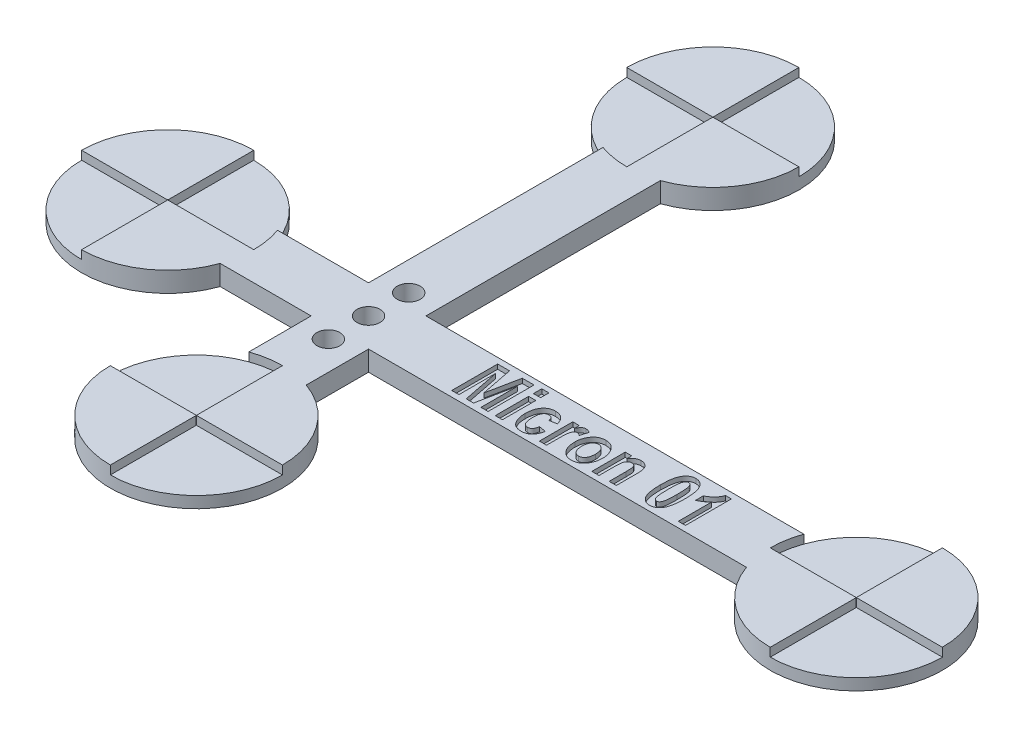
from build123d import *

# Parameters (mm, degrees)
BOSS_EXTRUDE1_DEPTH = 3.5
CUT_EXTRUDE1_DEPTH  = 1.5
SKETCH3_W           = 1.246753247
SKETCH3_H           = 1.454545455
SKETCH3_H_2         = 5.818181818
CUT_EXTRUDE2_DEPTH  = 0.8
SKETCH4_R           = 2
CUT_EXTRUDE3_DEPTH  = 4.5


with BuildPart() as part:
    # Sketch1 → Boss-Extrude1 (new body)
    with BuildSketch(Plane(origin=(0, 0, 0), x_dir=(1, 0, 0), z_dir=(0, 1, 0))):
        with BuildLine():
            Line((30, 45.857864376), (30, 5))
            Line((30, 5), (14.142135624, 5))
            ThreePointArc((14.142135624, 5), (-15, 0), (14.142135624, -5))
            Line((14.142135624, -5), (30, -5))
            Line((30, -5), (30, -15.857864376))
            ThreePointArc((30, -15.857864376), (35, -45), (40, -15.857864376))
            Line((40, -15.857864376), (40, -5))
            Line((40, -5), (105.857864376, -5))
            ThreePointArc((105.857864376, -5), (135, 0), (105.857864376, 5))
            Line((105.857864376, 5), (40, 5))
            Line((40, 5), (40, 45.857864376))
            ThreePointArc((40, 45.857864376), (35, 75), (30, 45.857864376))
        make_face()
    extrude(amount=BOSS_EXTRUDE1_DEPTH)

    # Sketch2 → Cut-Extrude1 (cut)
    with BuildSketch(Plane(origin=(0, 3.5, 0), x_dir=(1, 0, 0), z_dir=(0, 1, 0))):
        with BuildLine():
            Line((-15, 0), (-0.05, 0))
            ThreePointArc((-0.05, 0), (-0.035355339, 0.035355339), (0, 0.05))
            Line((0, 0.05), (0, 15))
            ThreePointArc((0, 15), (10.606601718, 10.606601718), (15, 0))
            Line((15, 0), (0.05, 0))
            ThreePointArc((0.05, 0), (0.035355339, -0.035355339), (0, -0.05))
            Line((0, -0.05), (0, -15))
            ThreePointArc((0, -15), (-10.606601718, -10.606601718), (-15, 0))
        make_face()
        with BuildLine():
            Line((35, 75), (35, 60.05))
            ThreePointArc((35, 60.05), (34.964644661, 60.035355339), (34.95, 60))
            Line((34.95, 60), (20, 60))
            ThreePointArc((20, 60), (24.393398282, 49.393398282), (35, 45))
            Line((35, 45), (35, 59.95))
            ThreePointArc((35, 59.95), (35.035355339, 59.964644661), (35.05, 60))
            Line((35.05, 60), (50, 60))
            ThreePointArc((50, 60), (45.606601718, 70.606601718), (35, 75))
        make_face()
        with BuildLine():
            Line((120, 15), (120, 0.05))
            ThreePointArc((120, 0.05), (120.035355339, 0.035355339), (120.05, 0))
            Line((120.05, 0), (135, 0))
            ThreePointArc((135, 0), (130.606601718, -10.606601718), (120, -15))
            Line((120, -15), (120, -0.05))
            ThreePointArc((120, -0.05), (119.964644661, -0.035355339), (119.95, 0))
            Line((119.95, 0), (105, 0))
            ThreePointArc((105, 0), (109.393398282, 10.606601718), (120, 15))
        make_face()
        with BuildLine():
            Line((20, -30), (34.95, -30))
            ThreePointArc((34.95, -30), (34.964644661, -30.035355339), (35, -30.05))
            Line((35, -30.05), (35, -45))
            ThreePointArc((35, -45), (45.606601718, -40.606601718), (50, -30))
            Line((50, -30), (35.05, -30))
            ThreePointArc((35.05, -30), (35.035355339, -29.964644661), (35, -29.95))
            Line((35, -29.95), (35, -15))
            ThreePointArc((35, -15), (24.393398282, -19.393398282), (20, -30))
        make_face()
    extrude(amount=-CUT_EXTRUDE1_DEPTH, mode=Mode.SUBTRACT)

    # Sketch3 → Cut-Extrude2 (cut)
    with BuildSketch(Plane(origin=(0, 3.5, 0), x_dir=(1, 0, 0), z_dir=(0, 1, 0))):
        Polygon((53.50036076, -4), (53.50036076, 4), (55.563672448, 4), (56.669191928, -1.561688312), (57.795815305, 4), (59.838023097, 4), (59.838023097, -4), (58.59126985, -4), (58.59126985, 2.400974026), (57.290945175, -4), (56.023088032, -4), (54.747114006, 2.400974026), (54.747114006, -4), align=None)
        with Locations((61.708152968, 3.376623377)):
            Rectangle(SKETCH3_W, SKETCH3_H)
        with Locations((61.708152968, -1.090909091)):
            Rectangle(SKETCH3_W, SKETCH3_H_2)
        with BuildLine():
            Line((67.734126993, 0.155844156), (66.487373747, -0.051948052))
            add(Edge.make_bspline(
                [(66.487373747, -0.051948052), (66.475238631, 0.013492139), (66.452160271, 0.137945199), (66.389179941, 0.307989308), (66.312160634, 0.454611766), (66.213055442, 0.573886506), (66.095416345, 0.667213464), (65.958609537, 0.733166985), (65.803936467, 0.772456922), (65.694860886, 0.776912369), (65.638347773, 0.779220779)],
                knots=[0, 0, 0, 0, 0.000199325, 0.000379073, 0.0005418, 0.000693948, 0.000840745, 0.000988855, 0.001146348, 0.001315678, 0.001315678, 0.001315678, 0.001315678], degree=3))
            add(Edge.make_bspline(
                [(65.638347773, 0.779220779), (65.600905429, 0.778062939), (65.527122523, 0.775781331), (65.420010496, 0.755102855), (65.317553938, 0.725549098), (65.222958212, 0.677663569), (65.130758823, 0.622007918), (65.046957124, 0.549315551), (64.968136169, 0.465515202), (64.894709448, 0.369037743), (64.827095322, 0.257785931), (64.770603047, 0.128257783), (64.725083376, -0.018687378), (64.68335517, -0.181979253), (64.653655963, -0.363419746), (64.633180941, -0.562384664), (64.620101663, -0.77850796), (64.618220871, -0.928551854), (64.617243876, -1.006493506)],
                knots=[0, 0, 0, 0, 0.000112201, 0.0002211, 0.00032637, 0.000430923, 0.000538128, 0.000648708, 0.000762403, 0.000882861, 0.001011764, 0.001152033, 0.001305535, 0.001472868, 0.001657284, 0.001856457, 0.002072757, 0.002306574, 0.002306574, 0.002306574, 0.002306574], degree=3))
            add(Edge.make_bspline(
                [(64.617243876, -1.006493506), (64.618261217, -1.092546265), (64.620213954, -1.257720471), (64.632711779, -1.496116795), (64.65538517, -1.714396148), (64.685469478, -1.914085761), (64.725675307, -2.093641007), (64.774055334, -2.254680712), (64.831596703, -2.395907747), (64.899086485, -2.518208897), (64.974173657, -2.623094471), (65.056196277, -2.712538943), (65.142228328, -2.791034021), (65.2374127, -2.851962864), (65.336627186, -2.901864568), (65.442857496, -2.935934853), (65.55464497, -2.95784839), (65.631749283, -2.959966029), (65.670815305, -2.961038961)],
                knots=[0, 0, 0, 0, 0.000258163, 0.000495531, 0.000715862, 0.000916302, 0.00110101, 0.001267389, 0.001420236, 0.001557572, 0.001685521, 0.001806187, 0.001921184, 0.002033748, 0.002144102, 0.002253448, 0.002367432, 0.002484495, 0.002484495, 0.002484495, 0.002484495], degree=3))
            add(Edge.make_bspline(
                [(65.670815305, -2.961038961), (65.72855094, -2.958115137), (65.840148837, -2.952463643), (65.998917272, -2.902884688), (66.141871425, -2.82385793), (66.244914469, -2.730611667), (66.318466989, -2.639969699), (66.370108431, -2.557981246), (66.418545215, -2.464077917), (66.462084604, -2.358060987), (66.501266248, -2.240396767), (66.534349316, -2.110465037), (66.565645908, -1.968673701), (66.582502685, -1.869672225), (66.59126985, -1.818181818)],
                knots=[0, 0, 0, 0, 0.000172842, 0.000334088, 0.000493972, 0.000659525, 0.000747247, 0.000843616, 0.000949622, 0.001063883, 0.001187088, 0.001321358, 0.001465921, 0.001622591, 0.001622591, 0.001622591, 0.001622591], degree=3))
            Line((66.59126985, -1.818181818), (67.838023097, -2.025974026))
            add(Edge.make_bspline(
                [(67.838023097, -2.025974026), (67.821015846, -2.110033143), (67.787894315, -2.273737832), (67.725282574, -2.51019173), (67.648292222, -2.729306841), (67.562922764, -2.933353422), (67.465367894, -3.120817392), (67.35648555, -3.292169834), (67.236010198, -3.447294215), (67.103969601, -3.586117196), (66.960430352, -3.708703947), (66.805564143, -3.814231607), (66.640086257, -3.904896068), (66.462835354, -3.977226655), (66.274845438, -4.034537616), (66.075882267, -4.074640125), (65.865713047, -4.099528833), (65.721752457, -4.102417816), (65.648088032, -4.103896104)],
                knots=[0, 0, 0, 0, 0.000257263, 0.000501018, 0.000733076, 0.000953485, 0.001164055, 0.001366255, 0.001561742, 0.001752349, 0.001940051, 0.002126916, 0.002313611, 0.002505046, 0.002700189, 0.002902356, 0.003113183, 0.003334111, 0.003334111, 0.003334111, 0.003334111], degree=3))
            add(Edge.make_bspline(
                [(65.648088032, -4.103896104), (65.554819841, -4.101887492), (65.37321271, -4.097976423), (65.110471697, -4.053593587), (64.864673186, -3.987367001), (64.639207309, -3.888476021), (64.431834059, -3.764176577), (64.243759839, -3.611361294), (64.073517705, -3.431602628), (63.925921273, -3.224317401), (63.795814013, -2.999463478), (63.681997355, -2.762165056), (63.585965745, -2.513438303), (63.506034653, -2.254410985), (63.446476255, -1.98270864), (63.403410095, -1.700737492), (63.374039392, -1.407542533), (63.371686907, -1.208406699), (63.37049063, -1.107142857)],
                knots=[0, 0, 0, 0, 0.000279523, 0.000544272, 0.000797144, 0.001041429, 0.001280302, 0.001520398, 0.001766145, 0.002020725, 0.002281892, 0.002544739, 0.002809429, 0.003081077, 0.00335717, 0.003643018, 0.003936526, 0.004240206, 0.004240206, 0.004240206, 0.004240206], degree=3))
            add(Edge.make_bspline(
                [(63.37049063, -1.107142857), (63.372239743, -0.987488549), (63.375640625, -0.75483916), (63.405336818, -0.417027711), (63.452726945, -0.100401237), (63.522926455, 0.193547978), (63.609847208, 0.466113039), (63.716501303, 0.716580192), (63.846096582, 0.943069469), (63.991820845, 1.149170928), (64.156114523, 1.330213011), (64.331961705, 1.489088097), (64.520060194, 1.623763244), (64.721234776, 1.733258723), (64.935011157, 1.818073271), (65.160732658, 1.877319248), (65.397782122, 1.916873853), (65.560259998, 1.920318934), (65.643217902, 1.922077922)],
                knots=[0, 0, 0, 0, 0.000358898, 0.000697823, 0.001016501, 0.00131851, 0.001603435, 0.001873935, 0.002133483, 0.002384849, 0.002629678, 0.002865336, 0.003094623, 0.003322001, 0.003550805, 0.003782743, 0.004021075, 0.004269712, 0.004269712, 0.004269712, 0.004269712], degree=3))
            add(Edge.make_bspline(
                [(65.643217902, 1.922077922), (65.71035858, 1.920846466), (65.841687336, 1.918437708), (66.034520622, 1.899106266), (66.217142954, 1.864581364), (66.391368457, 1.819675788), (66.554972261, 1.759740953), (66.709026878, 1.685791916), (66.853826329, 1.599814288), (66.98980103, 1.500415487), (67.115185036, 1.385394066), (67.233134509, 1.256930605), (67.340019014, 1.110862201), (67.439342218, 0.950708523), (67.526615855, 0.773374249), (67.606095879, 0.582082787), (67.676087051, 0.374743093), (67.714406275, 0.230221286), (67.734126993, 0.155844156)],
                knots=[0, 0, 0, 0, 0.000201403, 0.00039395, 0.000580532, 0.000758512, 0.000933129, 0.001102311, 0.00127047, 0.001437685, 0.001606618, 0.001780137, 0.00196001, 0.002148783, 0.002344802, 0.00255222, 0.002769885, 0.003000685, 0.003000685, 0.003000685, 0.003000685], degree=3))
        make_face()
        with BuildLine():
            Line((70.019841279, -4), (68.773088032, -4))
            Line((68.773088032, -4), (68.773088032, 1.818181818))
            Line((68.773088032, 1.818181818), (69.915945175, 1.818181818))
            Line((69.915945175, 1.818181818), (69.915945175, 0.991883117))
            add(Edge.make_bspline(
                [(69.915945175, 0.991883117), (69.940159399, 1.037952881), (69.986797897, 1.126686869), (70.05617644, 1.253336089), (70.123683954, 1.367923953), (70.192594719, 1.467096929), (70.254997633, 1.556811947), (70.319023898, 1.631359029), (70.379881779, 1.694731582), (70.457465413, 1.762170073), (70.560087337, 1.826053482), (70.691232303, 1.882473547), (70.832643067, 1.915363311), (70.929848968, 1.919815142), (70.979256863, 1.922077922)],
                knots=[0, 0, 0, 0, 0.000156131, 0.000300721, 0.000433243, 0.000554812, 0.000662946, 0.000760848, 0.000849244, 0.000926367, 0.001068679, 0.001209792, 0.001353128, 0.001501291, 0.001501291, 0.001501291, 0.001501291], degree=3))
            add(Edge.make_bspline(
                [(70.979256863, 1.922077922), (71.049468143, 1.91886318), (71.189930484, 1.912431875), (71.396264458, 1.852623193), (71.598585759, 1.762131289), (71.72239596, 1.675863479), (71.786075045, 1.631493506)],
                knots=[0, 0, 0, 0, 0.000210176, 0.00042047, 0.000639866, 0.000872208, 0.000872208, 0.000872208, 0.000872208], degree=3))
            Line((71.786075045, 1.631493506), (71.391594526, 0.319805195))
            add(Edge.make_bspline(
                [(71.391594526, 0.319805195), (71.343457298, 0.358255441), (71.252471756, 0.430931343), (71.106176233, 0.509110372), (70.96429064, 0.560954838), (70.869258342, 0.568020125), (70.823412708, 0.571428571)],
                knots=[0, 0, 0, 0, 0.000184416, 0.00034857, 0.000495904, 0.00063323, 0.00063323, 0.00063323, 0.00063323], degree=3))
            add(Edge.make_bspline(
                [(70.823412708, 0.571428571), (70.782505012, 0.569577552), (70.701066257, 0.565892554), (70.584319511, 0.525699903), (70.474380215, 0.46484784), (70.373247856, 0.375884101), (70.28120342, 0.255501948), (70.208770468, 0.094601523), (70.146148418, -0.102439271), (70.107437305, -0.295455124), (70.083085691, -0.477538767), (70.06505598, -0.645297865), (70.050951083, -0.839680763), (70.040281294, -1.060551746), (70.030100881, -1.307830134), (70.023930168, -1.582222395), (70.021131213, -1.883652001), (70.020282911, -2.093614232), (70.019841279, -2.202922078)],
                knots=[0, 0, 0, 0, 0.000122282, 0.000243439, 0.00036627, 0.000497452, 0.000644536, 0.000817347, 0.001023727, 0.001264102, 0.001406673, 0.001574831, 0.001770184, 0.001991255, 0.002238201, 0.002512628, 0.002814594, 0.00314252, 0.00314252, 0.00314252, 0.00314252], degree=3))
            Line((70.019841279, -2.202922078), (70.019841279, -4))
        make_face()
        with BuildLine():
            add(Edge.make_bspline(
                [(71.993867253, -1.00974026), (71.99773938, -0.871492577), (72.005358765, -0.599455473), (72.07087566, -0.202105645), (72.173904845, 0.177168447), (72.298261932, 0.475142281), (72.414852128, 0.700213025), (72.508933594, 0.858166819), (72.610211845, 1.0047968), (72.716400181, 1.140905493), (72.830224235, 1.265802708), (72.948905998, 1.380456268), (73.075551332, 1.483975824), (73.251872281, 1.606243165), (73.48640792, 1.734106031), (73.786697572, 1.843482079), (74.103960535, 1.910979968), (74.321452502, 1.918333961), (74.432178941, 1.922077922)],
                knots=[0, 0, 0, 0, 0.000414499, 0.00081563, 0.001204757, 0.001591247, 0.00178148, 0.00196495, 0.002142367, 0.002315787, 0.002482426, 0.002648908, 0.002810415, 0.002972534, 0.003292157, 0.00360852, 0.00392849, 0.004260331, 0.004260331, 0.004260331, 0.004260331], degree=3))
            add(Edge.make_bspline(
                [(74.432178941, 1.922077922), (74.524844362, 1.919080026), (74.706214487, 1.913212371), (74.970819979, 1.872921067), (75.219608224, 1.802229151), (75.453953528, 1.705294578), (75.670723745, 1.576365199), (75.874437856, 1.423442467), (76.059923504, 1.239208288), (76.228428557, 1.030627633), (76.37997441, 0.803981072), (76.513296238, 0.565748818), (76.625008798, 0.317712454), (76.719657136, 0.061815795), (76.787549524, -0.205805812), (76.840332848, -0.481537671), (76.871889339, -0.767122546), (76.87526987, -0.960420315), (76.876984136, -1.058441558)],
                knots=[0, 0, 0, 0, 0.000277982, 0.000544082, 0.000800519, 0.001052268, 0.001302568, 0.001555169, 0.001814604, 0.002084622, 0.002358372, 0.002631625, 0.002902613, 0.00317376, 0.003448993, 0.003729814, 0.004015574, 0.004309567, 0.004309567, 0.004309567, 0.004309567], degree=3))
            add(Edge.make_bspline(
                [(76.876984136, -1.058441558), (76.876227692, -1.131529258), (76.874729677, -1.276267575), (76.857345801, -1.490737935), (76.832372892, -1.700083082), (76.794451847, -1.904353031), (76.74632035, -2.102762528), (76.686787225, -2.295895078), (76.619804227, -2.484139081), (76.53955722, -2.665021822), (76.453170655, -2.838694854), (76.356567034, -3.000287959), (76.256676902, -3.152976813), (76.14667086, -3.291813358), (76.033747016, -3.423233057), (75.911462009, -3.541439921), (75.783056626, -3.649149424), (75.604551972, -3.775655653), (75.369934842, -3.906802618), (75.071483883, -4.020332864), (74.759616253, -4.091116904), (74.546182896, -4.0996153), (74.438672448, -4.103896104)],
                knots=[0, 0, 0, 0, 0.00021921, 0.00043411, 0.00064513, 0.000851458, 0.001056987, 0.001257262, 0.001457537, 0.001655994, 0.001850563, 0.002039049, 0.002220497, 0.002397475, 0.002570043, 0.002739947, 0.002907061, 0.003072374, 0.003395769, 0.003710226, 0.004027699, 0.00434993, 0.00434993, 0.00434993, 0.00434993], degree=3))
            add(Edge.make_bspline(
                [(74.438672448, -4.103896104), (74.352502729, -4.101341217), (74.183124459, -4.096319241), (73.934716636, -4.058456248), (73.698054839, -3.99479852), (73.472549003, -3.90676201), (73.258016744, -3.793542556), (73.054181778, -3.655526311), (72.864029071, -3.488983811), (72.683779026, -3.302138577), (72.520670531, -3.090331966), (72.380150134, -2.855461331), (72.258457363, -2.600481865), (72.162310721, -2.322961565), (72.085543251, -2.024985427), (72.033233234, -1.70496049), (72.000302919, -1.364326972), (71.996049016, -1.12994916), (71.993867253, -1.00974026)],
                knots=[0, 0, 0, 0, 0.000258443, 0.000508006, 0.000751761, 0.000992327, 0.001232686, 0.001478079, 0.001728994, 0.001989631, 0.002255885, 0.002529003, 0.002809298, 0.003101956, 0.003408675, 0.003731336, 0.004073787, 0.004434356, 0.004434356, 0.004434356, 0.004434356], degree=3))
        make_face()
        with BuildLine():
            add(Edge.make_bspline(
                [(73.2406205, -1.090909091), (73.241193573, -1.161301131), (73.242306492, -1.298003716), (73.261234707, -1.496347271), (73.288602558, -1.681695553), (73.324236438, -1.854514739), (73.376162408, -2.012893615), (73.434745234, -2.159458772), (73.506897923, -2.292206203), (73.589461187, -2.410648066), (73.680939517, -2.51464094), (73.776964817, -2.605361366), (73.875632321, -2.685555047), (73.982414792, -2.746314388), (74.091993225, -2.7960892), (74.205812587, -2.83181335), (74.324708332, -2.854023891), (74.405564639, -2.856089635), (74.446789331, -2.857142857)],
                knots=[0, 0, 0, 0, 0.000211095, 0.000409951, 0.000597062, 0.000773144, 0.000938458, 0.001096426, 0.001246068, 0.00139063, 0.001528684, 0.001660738, 0.001786746, 0.001908974, 0.002028146, 0.002147262, 0.002266036, 0.002389583, 0.002389583, 0.002389583, 0.002389583], degree=3))
            add(Edge.make_bspline(
                [(74.446789331, -2.857142857), (74.486930477, -2.856062286), (74.566168615, -2.853929251), (74.682924616, -2.831796204), (74.794636913, -2.796265769), (74.902095046, -2.746661195), (75.004819397, -2.682536946), (75.103605063, -2.604942025), (75.196824143, -2.512150646), (75.285902055, -2.407554507), (75.367452538, -2.288190002), (75.439332996, -2.15529938), (75.496230932, -2.007207398), (75.548090785, -1.84851973), (75.583928744, -1.674677795), (75.611733592, -1.488309881), (75.627963108, -1.288165559), (75.629460002, -1.150461681), (75.630230889, -1.079545455)],
                knots=[0, 0, 0, 0, 0.000120305, 0.000237481, 0.00035505, 0.000471266, 0.000591549, 0.000717557, 0.000847275, 0.000985501, 0.00112914, 0.00128021, 0.001437568, 0.001604429, 0.001780511, 0.001969228, 0.002169562, 0.00238228, 0.00238228, 0.00238228, 0.00238228], degree=3))
            add(Edge.make_bspline(
                [(75.630230889, -1.079545455), (75.629657673, -1.010234819), (75.628544962, -0.875690947), (75.609642621, -0.680588811), (75.582133444, -0.497953131), (75.546465486, -0.327351399), (75.49521573, -0.170068224), (75.433692654, -0.025632812), (75.362554163, 0.1072581), (75.279265313, 0.225728002), (75.188791642, 0.330494971), (75.093903874, 0.422586459), (74.99490702, 0.50126615), (74.890651683, 0.564846212), (74.782053107, 0.614109415), (74.669460084, 0.65026489), (74.551531628, 0.672061169), (74.471231571, 0.67422738), (74.430555565, 0.675324675)],
                knots=[0, 0, 0, 0, 0.000207849, 0.000403471, 0.000587372, 0.000761868, 0.000925636, 0.001082735, 0.001232376, 0.001376939, 0.001516219, 0.001647099, 0.001773107, 0.001894774, 0.002012466, 0.002130035, 0.002248808, 0.002370734, 0.002370734, 0.002370734, 0.002370734], degree=3))
            add(Edge.make_bspline(
                [(74.430555565, 0.675324675), (74.390416835, 0.674238638), (74.311183466, 0.672094813), (74.194392368, 0.650041164), (74.082343389, 0.614060182), (73.973968514, 0.565297339), (73.870848855, 0.500737434), (73.772125734, 0.422584114), (73.677081903, 0.331022603), (73.588667404, 0.225050714), (73.504100416, 0.107532851), (73.436606876, -0.027537366), (73.372844625, -0.171655992), (73.32568136, -0.331268167), (73.285792867, -0.502358852), (73.261951191, -0.687847561), (73.242143614, -0.884859588), (73.241136929, -1.021045607), (73.2406205, -1.090909091)],
                knots=[0, 0, 0, 0, 0.000120305, 0.000237481, 0.00035505, 0.000472742, 0.000593025, 0.000719033, 0.000849914, 0.000988139, 0.001132702, 0.001283011, 0.00144011, 0.001604937, 0.00178137, 0.001966642, 0.002165497, 0.002374969, 0.002374969, 0.002374969, 0.002374969], degree=3))
        make_face(mode=Mode.SUBTRACT)
        with BuildLine():
            Line((82.175685435, -4), (80.928932188, -4))
            Line((80.928932188, -4), (80.928932188, -1.025974026))
            add(Edge.make_bspline(
                [(80.928932188, -1.025974026), (80.92854282, -0.954543529), (80.927799442, -0.818169062), (80.924356954, -0.622819841), (80.920247564, -0.445806445), (80.911867341, -0.287253276), (80.902241106, -0.147618119), (80.891650159, -0.026736408), (80.87710847, 0.075056785), (80.856368171, 0.184335425), (80.821004006, 0.301543782), (80.764596313, 0.426141455), (80.692774231, 0.534382367), (80.604019629, 0.62160385), (80.506619056, 0.69206755), (80.401915582, 0.743240838), (80.289966246, 0.77397023), (80.213215912, 0.777447079), (80.174062058, 0.779220779)],
                knots=[0, 0, 0, 0, 0.000214292, 0.000409124, 0.000586139, 0.000745437, 0.000885387, 0.001006053, 0.001109364, 0.001193733, 0.001339584, 0.001475415, 0.001602837, 0.00172681, 0.001846644, 0.001962086, 0.002074709, 0.002191998, 0.002191998, 0.002191998, 0.002191998], degree=3))
            add(Edge.make_bspline(
                [(80.174062058, 0.779220779), (80.123447016, 0.776869331), (80.023371597, 0.772220076), (79.878191919, 0.730407315), (79.739286208, 0.667322233), (79.612395844, 0.575023409), (79.495650377, 0.46328544), (79.398737064, 0.328262501), (79.317469986, 0.175298829), (79.268630692, 0.030618942), (79.236032455, -0.101357957), (79.218310317, -0.222713773), (79.199402097, -0.363228665), (79.188161741, -0.524290952), (79.175994029, -0.704955422), (79.168471275, -0.905793407), (79.163505023, -1.126597226), (79.162974738, -1.280299629), (79.162698422, -1.36038961)],
                knots=[0, 0, 0, 0, 0.000151532, 0.000299606, 0.000449951, 0.00060715, 0.000767873, 0.000932819, 0.001103467, 0.001285727, 0.00138928, 0.001510979, 0.001653337, 0.001814575, 0.001995128, 0.00219659, 0.002417423, 0.002657688, 0.002657688, 0.002657688, 0.002657688], degree=3))
            Line((79.162698422, -1.36038961), (79.162698422, -4))
            Line((79.162698422, -4), (77.915945175, -4))
            Line((77.915945175, -4), (77.915945175, 1.818181818))
            Line((77.915945175, 1.818181818), (79.058802318, 1.818181818))
            Line((79.058802318, 1.818181818), (79.058802318, 0.965909091))
            add(Edge.make_bspline(
                [(79.058802318, 0.965909091), (79.109710936, 1.041759386), (79.208544913, 1.189015129), (79.378208436, 1.383777654), (79.556148861, 1.549983921), (79.743871586, 1.687067674), (79.943914365, 1.791672469), (80.153616398, 1.866743358), (80.373756253, 1.914536504), (80.524465529, 1.919537791), (80.60101011, 1.922077922)],
                knots=[0, 0, 0, 0, 0.000273831, 0.000531616, 0.00077285, 0.001003084, 0.001226733, 0.001447536, 0.001669767, 0.001899129, 0.001899129, 0.001899129, 0.001899129], degree=3))
            add(Edge.make_bspline(
                [(80.60101011, 1.922077922), (80.688429859, 1.918919658), (80.857463892, 1.912812868), (81.100755155, 1.857826735), (81.32221213, 1.766788484), (81.519497148, 1.639484009), (81.693501252, 1.488180451), (81.837925118, 1.311212589), (81.955005756, 1.115344188), (82.024073318, 0.933951844), (82.069245622, 0.777526046), (82.097815568, 0.646198938), (82.122467785, 0.502145243), (82.140849457, 0.345447453), (82.157608055, 0.176651439), (82.168642166, -0.004744055), (82.17517168, -0.198542646), (82.175511007, -0.332245522), (82.175685435, -0.400974026)],
                knots=[0, 0, 0, 0, 0.000261973, 0.000506549, 0.000743812, 0.00097664, 0.00120785, 0.001432751, 0.0016591, 0.001889414, 0.002012726, 0.002147427, 0.002292345, 0.002451013, 0.002620623, 0.002801175, 0.002996089, 0.003202264, 0.003202264, 0.003202264, 0.003202264], degree=3))
            Line((82.175685435, -0.400974026), (82.175685435, -4))
        make_face()
        with BuildLine():
            add(Edge.make_bspline(
                [(88.042568552, 4), (88.120143484, 3.997148674), (88.273215628, 3.991522391), (88.496552113, 3.948267667), (88.709167709, 3.877994443), (88.909593475, 3.778303449), (89.097951861, 3.649902676), (89.274716094, 3.493575316), (89.44002471, 3.309388361), (89.594940829, 3.095688722), (89.734153575, 2.845756266), (89.853050654, 2.555093261), (89.952904602, 2.222696136), (90.034271056, 1.848605187), (90.098816614, 1.432288922), (90.142527697, 0.973709188), (90.170357365, 0.473287901), (90.173862882, 0.125581293), (90.175685435, -0.055194805)],
                knots=[0, 0, 0, 0, 0.000232602, 0.000458974, 0.000679718, 0.0009026, 0.001128179, 0.00136168, 0.001608802, 0.001869231, 0.002151946, 0.002464883, 0.002809456, 0.003191901, 0.003612528, 0.004072572, 0.004573333, 0.005115628, 0.005115628, 0.005115628, 0.005115628], degree=3))
            add(Edge.make_bspline(
                [(90.175685435, -0.055194805), (90.173858892, -0.235429027), (90.170346113, -0.582052681), (90.14257855, -1.080864069), (90.098621978, -1.538317484), (90.034600767, -1.953666632), (89.952257764, -2.327486698), (89.853811541, -2.659813141), (89.733670888, -2.949980575), (89.595090938, -3.199694145), (89.439887399, -3.412685451), (89.276378827, -3.597979093), (89.099525864, -3.753792128), (88.911527253, -3.881710441), (88.71208139, -3.98233668), (88.500748445, -4.05159659), (88.278700656, -4.095734493), (88.126655602, -4.101138343), (88.049062058, -4.103896104)],
                knots=[0, 0, 0, 0, 0.000540672, 0.001039812, 0.00149824, 0.001918867, 0.002299728, 0.002645854, 0.002957293, 0.003240007, 0.003500437, 0.003746473, 0.003979974, 0.004205554, 0.004426982, 0.004647726, 0.004870909, 0.005103511, 0.005103511, 0.005103511, 0.005103511], degree=3))
            add(Edge.make_bspline(
                [(88.049062058, -4.103896104), (87.971520172, -4.100862637), (87.818612265, -4.094880825), (87.59489671, -4.054282938), (87.382435066, -3.983452229), (87.182511086, -3.883672907), (86.993665393, -3.757214281), (86.816991446, -3.602360262), (86.651459776, -3.419950023), (86.525616278, -3.246353686), (86.430990718, -3.092878847), (86.364980322, -2.964508803), (86.303455869, -2.825479381), (86.244235797, -2.676576112), (86.19349064, -2.514885831), (86.144536647, -2.343474895), (86.100591604, -2.160968409), (86.062673394, -1.967931987), (86.02559404, -1.76477297), (85.998032431, -1.550003327), (85.97076078, -1.325090023), (85.952664467, -1.088321983), (85.93572137, -0.841612758), (85.925283351, -0.583390093), (85.915909942, -0.315001944), (85.915933294, -0.132043959), (85.915945175, -0.038961039)],
                knots=[0, 0, 0, 0, 0.000232602, 0.000458677, 0.000679421, 0.000902303, 0.001126975, 0.001359407, 0.001605326, 0.001864441, 0.002001422, 0.002145912, 0.00229706, 0.002457438, 0.002626339, 0.002805176, 0.002992203, 0.003189274, 0.003395315, 0.003611584, 0.003838724, 0.004074918, 0.004323825, 0.00458057, 0.004850172, 0.005129398, 0.005129398, 0.005129398, 0.005129398], degree=3))
            add(Edge.make_bspline(
                [(85.915945175, -0.038961039), (85.917766425, 0.140733062), (85.92126861, 0.486277146), (85.949096706, 0.983455445), (85.992786068, 1.438795514), (86.057455354, 1.852398974), (86.139031184, 2.224773358), (86.238156972, 2.556355193), (86.357927524, 2.84609395), (86.496547236, 3.095795814), (86.651741372, 3.308789888), (86.815252237, 3.494082856), (86.992104631, 3.649896058), (87.180103387, 3.777814329), (87.379549212, 3.878440579), (87.590882167, 3.947700486), (87.812929954, 3.99183839), (87.964975007, 3.997242239), (88.042568552, 4)],
                knots=[0, 0, 0, 0, 0.000539049, 0.001036568, 0.001493381, 0.0019108, 0.002291661, 0.002636234, 0.002947673, 0.003230387, 0.003490817, 0.003736853, 0.003970355, 0.004195934, 0.004417363, 0.004638106, 0.004861289, 0.005093891, 0.005093891, 0.005093891, 0.005093891], degree=3))
        make_face()
        with BuildLine():
            add(Edge.make_bspline(
                [(88.045815305, 2.753246753), (88.016983802, 2.751588419), (87.959509622, 2.748282613), (87.875927262, 2.724571332), (87.79639698, 2.686845816), (87.722427151, 2.631936572), (87.654531179, 2.560572149), (87.589331771, 2.475933398), (87.529382821, 2.37557449), (87.471821912, 2.257031527), (87.422907436, 2.108173752), (87.379831447, 1.922528032), (87.345944957, 1.69496366), (87.317590249, 1.425720345), (87.292957589, 1.115056325), (87.278036586, 0.762026881), (87.268158161, 0.367481909), (87.267133043, 0.090375275), (87.266594526, -0.055194805)],
                knots=[0, 0, 0, 0, 8.6421e-05, 0.000172276, 0.000258682, 0.000349271, 0.00044685, 0.000553351, 0.00066917, 0.000796964, 0.000947894, 0.001138079, 0.00136814, 0.001637587, 0.001950225, 0.002302871, 0.002697472, 0.003134172, 0.003134172, 0.003134172, 0.003134172], degree=3))
            add(Edge.make_bspline(
                [(87.266594526, -0.055194805), (87.267123328, -0.200765322), (87.268127989, -0.477331814), (87.278100069, -0.871330634), (87.29283468, -1.223292397), (87.317841907, -1.533920343), (87.34564763, -1.80268425), (87.37998794, -2.030198873), (87.42300039, -2.215269381), (87.471382223, -2.36384325), (87.52979398, -2.481451586), (87.589390764, -2.581371854), (87.653964499, -2.666118067), (87.722995564, -2.735808707), (87.79633331, -2.790804977), (87.875943778, -2.828451078), (87.959505472, -2.852182826), (88.016982415, -2.855485896), (88.045815305, -2.857142857)],
                knots=[0, 0, 0, 0, 0.0004367, 0.000829678, 0.001182325, 0.001493344, 0.001764405, 0.001992863, 0.002183047, 0.002333978, 0.002460309, 0.002576128, 0.002682629, 0.002779053, 0.002869643, 0.002956049, 0.003041904, 0.003128325, 0.003128325, 0.003128325, 0.003128325], degree=3))
            add(Edge.make_bspline(
                [(88.045815305, -2.857142857), (88.075188368, -2.85552029), (88.133206372, -2.852315378), (88.21738504, -2.828542533), (88.297029049, -2.790253808), (88.372435814, -2.736496976), (88.439646108, -2.664443264), (88.506337432, -2.581825172), (88.563423586, -2.480471516), (88.621525538, -2.362653873), (88.670754282, -2.213878514), (88.710709098, -2.027621166), (88.748134759, -1.800724279), (88.775757394, -1.53179805), (88.798173843, -1.221589379), (88.813727392, -0.869719468), (88.823431124, -0.476245826), (88.824483267, -0.20022291), (88.825036084, -0.055194805)],
                knots=[0, 0, 0, 0, 8.8037e-05, 0.000173892, 0.000260298, 0.000352202, 0.00044978, 0.000554999, 0.000669985, 0.000797778, 0.000948709, 0.001138526, 0.001368845, 0.001638291, 0.001949188, 0.002301835, 0.002694813, 0.00312989, 0.00312989, 0.00312989, 0.00312989], degree=3))
            add(Edge.make_bspline(
                [(88.825036084, -0.055194805), (88.824478904, 0.090374192), (88.823418258, 0.367478764), (88.813778191, 0.762037569), (88.798092676, 1.114981824), (88.775844364, 1.425743409), (88.748129467, 1.695205512), (88.710705916, 1.922098251), (88.670766677, 2.108368799), (88.621491087, 2.257107732), (88.563526869, 2.37503186), (88.505793041, 2.476420917), (88.440190416, 2.560429298), (88.372374904, 2.632553578), (88.297043894, 2.68636923), (88.217381216, 2.724643459), (88.133207354, 2.748420037), (88.075188698, 2.751624443), (88.045815305, 2.753246753)],
                knots=[0, 0, 0, 0, 0.0004367, 0.000831301, 0.001183948, 0.001496464, 0.00176591, 0.001996229, 0.002186046, 0.002336977, 0.00246477, 0.002579756, 0.002686257, 0.002783835, 0.002875739, 0.002962145, 0.003048, 0.003136037, 0.003136037, 0.003136037, 0.003136037], degree=3))
        make_face(mode=Mode.SUBTRACT)
        with BuildLine():
            Line((94.227633487, -4), (92.98088024, -4))
            Line((92.98088024, -4), (92.98088024, 1.818181818))
            add(Edge.make_bspline(
                [(92.98088024, 1.818181818), (92.920412972, 1.754730911), (92.800492224, 1.62889291), (92.60970715, 1.453218367), (92.412323734, 1.291255562), (92.207039522, 1.142270202), (91.996203452, 1.00484821), (91.777148311, 0.88080675), (91.551731573, 0.769886835), (91.396328368, 0.706868155), (91.318542578, 0.675324675)],
                knots=[0, 0, 0, 0, 0.000262892, 0.000521376, 0.000777458, 0.001028458, 0.001281964, 0.001532049, 0.001783253, 0.002035002, 0.002035002, 0.002035002, 0.002035002], degree=3))
            Line((91.318542578, 0.675324675), (91.318542578, 2.025974026))
            add(Edge.make_bspline(
                [(91.318542578, 2.025974026), (91.408202361, 2.065822815), (91.594868962, 2.14878574), (91.86795252, 2.315358029), (92.143755905, 2.523954722), (92.372604729, 2.724191127), (92.5510984, 2.902341801), (92.678281486, 3.042657431), (92.792143141, 3.19086366), (92.897663858, 3.341670183), (92.990831748, 3.499389644), (93.073085968, 3.660994237), (93.146073949, 3.827538141), (93.184145798, 3.942309498), (93.203282837, 4)],
                knots=[0, 0, 0, 0, 0.000294118, 0.000612337, 0.000956818, 0.001330664, 0.001523511, 0.001713196, 0.00189829, 0.002083817, 0.002265062, 0.002447293, 0.002627626, 0.002809886, 0.002809886, 0.002809886, 0.002809886], degree=3))
            Line((93.203282837, 4), (94.227633487, 4))
            Line((94.227633487, 4), (94.227633487, -4))
        make_face()
    extrude(amount=-CUT_EXTRUDE2_DEPTH, mode=Mode.SUBTRACT)

    # Sketch4 → Cut-Extrude3 (cut, through all)
    with BuildSketch(Plane(origin=(0, 3.5, 0), x_dir=(1, 0, 0), z_dir=(0, 1, 0))):
        with Locations((35, 0)):
            Circle(SKETCH4_R)
        with Locations((35, 7)):
            Circle(SKETCH4_R)
        with Locations((35, -7)):
            Circle(SKETCH4_R)
    extrude(amount=-CUT_EXTRUDE3_DEPTH, mode=Mode.SUBTRACT)


solid = part.part
